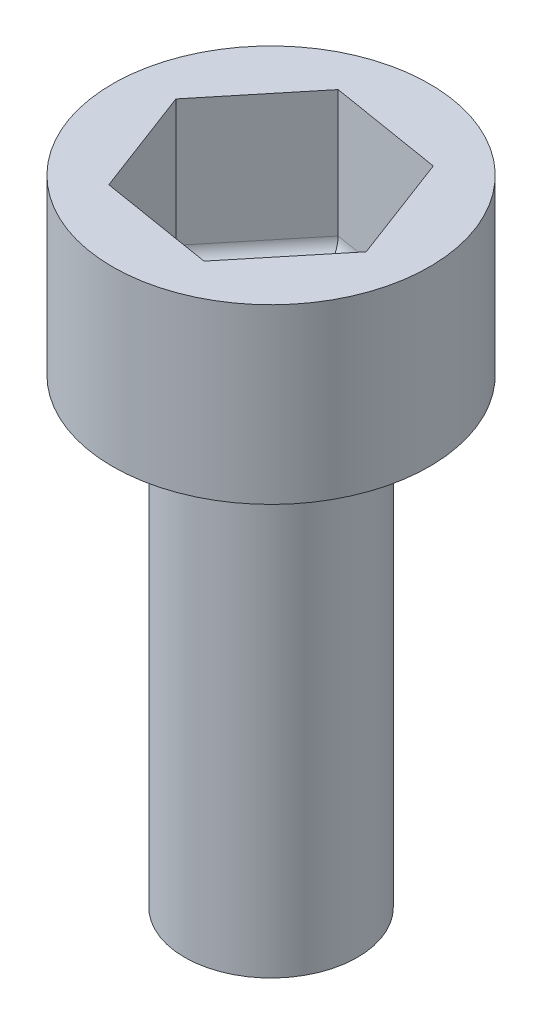
from build123d import *

# Parameters (mm, degrees)
SKETCH_1_R          = 1.5
EXTRUDE_1_DEPTH     = 8
SKETCH_2_R          = 2.75
EXTRUDE_2_DEPTH     = 3
CUT_EXTRUDE_1_DEPTH = 2.5
FILLET_1_R          = 0.3


with BuildPart() as part:
    # 草图1 → 凸台-拉伸1 (new body)
    with BuildSketch(Plane(origin=(0, 0, 0), x_dir=(1, 0, 0), z_dir=(0, 1, 0))):
        Circle(SKETCH_1_R)
    extrude(amount=EXTRUDE_1_DEPTH)

    # 草图2 → 凸台-拉伸2 (add)
    with BuildSketch(Plane(origin=(0, 8, 0), x_dir=(1, 0, 0), z_dir=(0, 1, 0))):
        Circle(SKETCH_2_R)
    extrude(amount=EXTRUDE_2_DEPTH)

    # 草图3 → 切除-拉伸1 (cut)
    with BuildSketch(Plane(origin=(0, 11, 0), x_dir=(1, 0, 0), z_dir=(0, 1, 0))):
        Polygon((1.973732301, -0.323080184), (1.266661797, 1.54776222), (-0.707070503, 1.870842405), (-1.973732301, 0.323080184), (-1.266661797, -1.54776222), (0.707070503, -1.870842405), align=None)
    extrude(amount=-CUT_EXTRUDE_1_DEPTH, mode=Mode.SUBTRACT)

    # 圆角1
    fillet_1_edges = [part.edges().sort_by_distance(p)[0] for p in [
        (1.340401402, 8.5, 1.096961295),
        (-0.279795647, 8.5, 1.709302313),
        (-1.620197049, 8.5, 0.612341018),
        (-1.340401402, 8.5, -1.096961295),
        (0.279795647, 8.5, -1.709302313),
        (1.620197049, 8.5, -0.612341018),
    ]]
    fillet(fillet_1_edges, radius=FILLET_1_R)


solid = part.part
